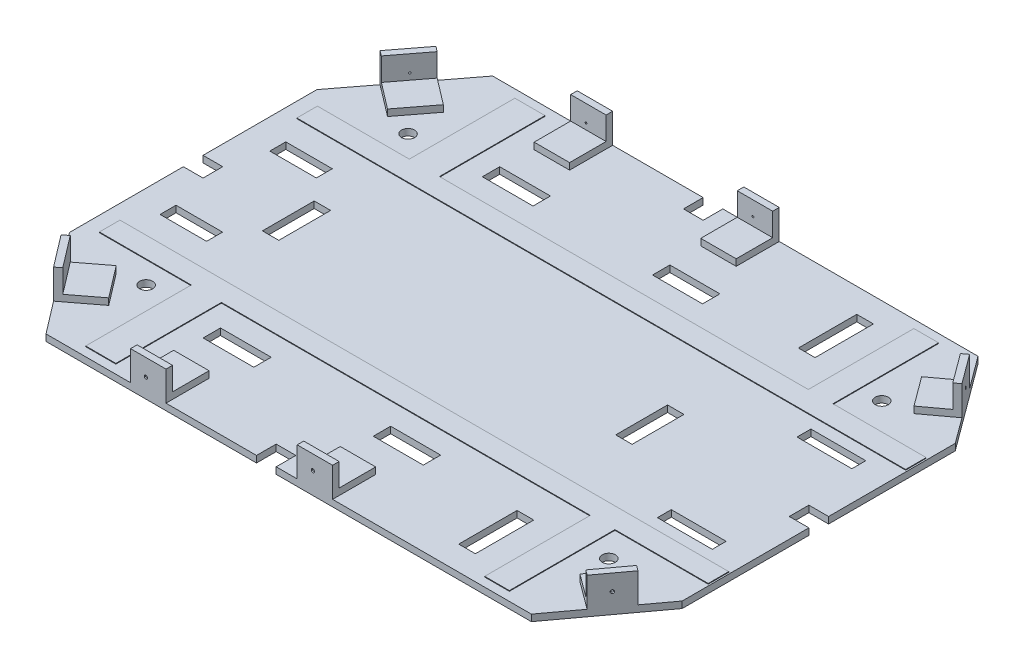
from build123d import *

# Parameters (mm, degrees)
BOSS_EXTRUDE1_DEPTH                               = 10
BOSS_EXTRUDE3_DEPTH                               = 1
SKETCH4_W                                         = 54.012676008
SKETCH4_H                                         = 70.658513541
SKETCH4_W_2                                       = 54
BOSS_EXTRUDE4_DEPTH                               = 10
SKETCH5_W                                         = 54
SKETCH5_H                                         = 56.816879392
SKETCH5_W_2                                       = 54.121672763
BOSS_EXTRUDE6_DEPTH                               = 3
SKETCH6_R                                         = 3
CUT_EXTRUDE1_DEPTH                                = 3
BOSS_EXTRUDE7_DEPTH                               = 3
SKETCH8_R                                         = 3
CUT_EXTRUDE6_DEPTH                                = 10
SKETCH9_W                                         = 60.69706817
SKETCH9_H                                         = 59.255494523
BOSS_EXTRUDE8_DEPTH                               = 3
SKETCH10_R                                        = 3
CUT_EXTRUDE7_DEPTH                                = 10
SKETCH12_R                                        = 10
SKETCH12_W                                        = 77.312261737
SKETCH12_H                                        = 26.476801965
SKETCH12_W_2                                      = 76.253189659
SKETCH12_W_3                                      = 25.417729886
SKETCH12_H_2                                      = 88.962054601
SKETCH12_W_4                                      = 83.666694209
SKETCH12_H_3                                      = 21.181441572
SKETCH12_W_5                                      = 70.957829266
SKETCH12_H_4                                      = 24.358657807
SKETCH12_W_6                                      = 25
SKETCH12_H_5                                      = 75
CUT_EXTRUDE8_DEPTH                                = 10
SKETCH13_W                                        = 30
SKETCH13_H                                        = 20
SKETCH13_W_2                                      = 20
SKETCH13_H_2                                      = 30
CUT_EXTRUDE9_DEPTH                                = 11
CUT_EXTRUDE11_DEPTH                               = 70
CUT_EXTRUDE11_DEPTH_BACK                          = 10
SKETCH16_W                                        = 54.012676008
SKETCH16_H                                        = 45
SKETCH16_W_2                                      = 54
BOSS_EXTRUDE9_DEPTH                               = 10
SKETCH18_W                                        = 60.806808494
SKETCH18_H                                        = 45
BOSS_EXTRUDE10_DEPTH                              = 10
CSK_FOR_3_FLAT_HEAD_MACHINE_SCREW_100_D           = 2.794
CSK_FOR_3_FLAT_HEAD_MACHINE_SCREW_100_DEPTH       = 10
CSK_FOR_3_FLAT_HEAD_MACHINE_SCREW_100_CSINK_D     = 5.0546
CSK_FOR_3_FLAT_HEAD_MACHINE_SCREW_100_CSINK_ANGLE = 100
SKETCH20_W                                        = 55.396415353
SKETCH20_H                                        = 45
BOSS_EXTRUDE11_DEPTH                              = 10
CSK_FOR_3_FLAT_HEAD_MACHINE_SCREW_2_D             = 2.794
CSK_FOR_3_FLAT_HEAD_MACHINE_SCREW_2_DEPTH         = 10
CSK_FOR_3_FLAT_HEAD_MACHINE_SCREW_2_CSINK_D       = 5.0546
CSK_FOR_3_FLAT_HEAD_MACHINE_SCREW_2_CSINK_ANGLE   = 100
CSK_FOR_3_FLAT_HEAD_MACHINE_SCREW_3_D             = 2.794
CSK_FOR_3_FLAT_HEAD_MACHINE_SCREW_3_DEPTH         = 10
CSK_FOR_3_FLAT_HEAD_MACHINE_SCREW_3_CSINK_D       = 5.0546
CSK_FOR_3_FLAT_HEAD_MACHINE_SCREW_3_CSINK_ANGLE   = 100


with BuildPart() as part:
    # Sketch2 → Boss-Extrude1 (new body)
    with BuildSketch(Plane(origin=(0, 0, 0), x_dir=(1, 0, 0), z_dir=(0, 1, 0))):
        Polygon((0, -190.295), (0, 190.295), (118.58, 345.487717935), (863.58, 345.487717935), (963.71, 209.828898833), (963.71, -209.828898833), (863.58, -345.487717935), (118.58, -345.487717935), align=None)
    extrude(amount=BOSS_EXTRUDE1_DEPTH)

    # Sketch3 → Boss-Extrude3 (add)
    with BuildSketch(Plane(origin=(0, 10, 0), x_dir=(1, 0, 0), z_dir=(0, 1, 0))):
        Polygon((28.17698589, 166.19612069), (168.241641063, 166.19612069), (168.241641063, 327.165948276), (214.233020373, 327.165948276), (214.233020373, 166.19612069), (776.582158304, 166.19612069), (776.582158304, 327.165948276), (814.211468649, 327.165948276), (814.211468649, 166.19612069), (956.366641063, 166.19612069), (956.366641063, 134.838362069), (28.17698589, 134.838362069), align=None)
        Polygon((28.17698589, -166.19612069), (28.17698589, -134.838362069), (956.366641063, -134.838362069), (956.366641063, -166.19612069), (814.211468649, -166.19612069), (814.211468649, -327.165948276), (776.582158304, -327.165948276), (776.582158304, -166.19612069), (214.233020373, -166.19612069), (214.233020373, -327.165948276), (168.241641063, -327.165948276), (168.241641063, -166.19612069), align=None)
    extrude(amount=BOSS_EXTRUDE3_DEPTH)

    # Sketch4 → Boss-Extrude4 (add)
    with BuildSketch(Plane(origin=(0, 10, 0), x_dir=(1, 0, 0), z_dir=(0, 1, 0))):
        with Locations((277.006338004, 310.158461165)):
            Rectangle(SKETCH4_W, SKETCH4_H)
        with Locations((531.012676008, 310.158461165)):
            Rectangle(SKETCH4_W_2, SKETCH4_H)
        Polygon((42.789166451, 246.295734017), (94.437964084, 206.831804878), (131.289422503, 255.061506276), (79.640624869, 294.525435415), align=None)
        Polygon((901.195345486, 294.525435415), (855.113704325, 260.512499433), (888.011178195, 215.942116364), (934.092819357, 249.955052346), align=None)
        with Locations((531.012676008, -310.158461165)):
            Rectangle(SKETCH4_W_2, SKETCH4_H)
        Polygon((42.789166451, -246.295734017), (94.437964084, -206.831804878), (131.289422503, -255.061506276), (79.640624869, -294.525435415), align=None)
        Polygon((901.195345486, -294.525435415), (855.113704325, -260.512499433), (888.011178195, -215.942116364), (934.092819357, -249.955052346), align=None)
        with Locations((277.006338004, -310.158461165)):
            Rectangle(SKETCH4_W, SKETCH4_H)
    extrude(amount=BOSS_EXTRUDE4_DEPTH)

    # Sketch5 → Boss-Extrude6 (add)
    with BuildSketch(Plane.XY.offset(345.487717935)):
        with Locations((277, 38.408439696)):
            Rectangle(SKETCH5_W, SKETCH5_H)
        with Locations((531.07351239, 38.408439696)):
            Rectangle(SKETCH5_W_2, SKETCH5_H)
    boss_extrude6 = extrude(amount=-BOSS_EXTRUDE6_DEPTH)

    # Sketch6 → Cut-Extrude1 (cut)
    with BuildSketch(Plane.XY.offset(345.487717935)):
        with Locations((277, 40.573565098)):
            Circle(SKETCH6_R)
        with Locations((531.134348771, 40.573565098)):
            Circle(SKETCH6_R)
    cut_extrude1 = extrude(amount=-CUT_EXTRUDE1_DEPTH, mode=Mode.SUBTRACT)

    # Mirror3: Boss-Extrude6, Cut-Extrude1 across plane
    add(boss_extrude6.mirror(Plane.XY))
    add(cut_extrude1.mirror(Plane.XY), mode=Mode.SUBTRACT)

    # Sketch7 → Boss-Extrude7 (add)
    with BuildSketch(Plane(origin=(724.099790673, 0, 534.459259784), x_dir=(0.593855643, 0, -0.80457161), z_dir=(0.80457161, 0, 0.593855643))):
        Polygon((298.213137891, 10), (298.213137891, 0), (353.439734487, 0), (353.439734487, 10), (353.439734487, 60.62673412), (298.213137891, 60.62673412), align=None)
    boss_extrude7 = extrude(amount=-BOSS_EXTRUDE7_DEPTH)

    # Sketch8 → Cut-Extrude6 (cut)
    with BuildSketch(Plane(origin=(721.686075844, 0, 532.677692854), x_dir=(-0.593855643, 0, 0.80457161), z_dir=(-0.80457161, 0, -0.593855643))):
        with Locations((-325.213137891, 37)):
            Circle(SKETCH8_R)
    cut_extrude6 = extrude(amount=-CUT_EXTRUDE6_DEPTH, mode=Mode.SUBTRACT)

    # Sketch9 → Boss-Extrude8 (add)
    with BuildSketch(Plane(origin=(-91.803915054, 0, 70.14574132), x_dir=(0.607137371, 0, 0.794596887), z_dir=(-0.794596887, 0, 0.607137371))):
        with Locations((252.033259576, 29.627747262)):
            Rectangle(SKETCH9_W, SKETCH9_H)
    boss_extrude8 = extrude(amount=-BOSS_EXTRUDE8_DEPTH)

    # Sketch10 → Cut-Extrude7 (cut)
    with BuildSketch(Plane(origin=(-91.803915054, 0, 70.14574132), x_dir=(0.607137371, 0, 0.794596887), z_dir=(-0.794596887, 0, 0.607137371))):
        with Locations((255.381793661, 38.737565601)):
            Circle(SKETCH10_R)
    cut_extrude7 = extrude(amount=-CUT_EXTRUDE7_DEPTH, mode=Mode.SUBTRACT)

    # Mirror4: Boss-Extrude7, Cut-Extrude6, Boss-Extrude8, Cut-Extrude7 across plane
    add(boss_extrude7.mirror(Plane.XY))
    add(cut_extrude6.mirror(Plane.XY), mode=Mode.SUBTRACT)
    add(boss_extrude8.mirror(Plane.XY))
    add(cut_extrude7.mirror(Plane.XY), mode=Mode.SUBTRACT)

    # Sketch12 → Cut-Extrude8 (cut)
    with BuildSketch(Plane(origin=(0, 10, 0), x_dir=(1, 0, 0), z_dir=(0, 1, 0))):
        with Locations((132.890750104, 199.635086814)):
            Circle(SKETCH12_R)
        with Locations((846.705331075, 208.107663443)):
            Circle(SKETCH12_R)
        with Locations((284.867593382, 212.873487797)):
            Rectangle(SKETCH12_W, SKETCH12_H)
        with Locations((543.810716598, 212.873487797)):
            Rectangle(SKETCH12_W_2, SKETCH12_H)
        with Locations((725.971114115, 258.943123216)):
            Rectangle(SKETCH12_W_3, SKETCH12_H_2)
        with Locations((871.593524922, 106.436743898)):
            Rectangle(SKETCH12_W_4, SKETCH12_H_3)
        with Locations((85.762042607, 83.666694209)):
            Rectangle(SKETCH12_W_5, SKETCH12_H_4)
        with Locations((162.5, -2.012282065)):
            Rectangle(SKETCH12_W_6, SKETCH12_H_5)
        with Locations((701.21, -2.012282065)):
            Rectangle(SKETCH12_W_6, SKETCH12_H_5)
    cut_extrude8 = extrude(amount=-CUT_EXTRUDE8_DEPTH, mode=Mode.SUBTRACT)

    # Mirror5: Cut-Extrude8 across plane
    add(cut_extrude8.mirror(Plane.XY), mode=Mode.SUBTRACT)

    # Sketch13 → Cut-Extrude9 (cut, through all)
    with BuildSketch(Plane(origin=(0, 10, 0), x_dir=(1, 0, 0), z_dir=(0, 1, 0))):
        with Locations((15, 0)):
            Rectangle(SKETCH13_W, SKETCH13_H)
        with Locations((948.71, 0)):
            Rectangle(SKETCH13_W, SKETCH13_H)
        with Locations((457, -330.487717935)):
            Rectangle(SKETCH13_W_2, SKETCH13_H_2)
        with Locations((457, 330.487717935)):
            Rectangle(SKETCH13_W_2, SKETCH13_H_2)
    extrude(amount=-CUT_EXTRUDE9_DEPTH, mode=Mode.SUBTRACT)

    # Sketch15 → Cut-Extrude11 (cut, two sides)
    with BuildSketch(Plane(origin=(0, 10, 0), x_dir=(1, 0, 0), z_dir=(0, 1, 0))) as cut_extrude11_sk:
        Polygon((0, 10), (30, 10), (30, -10), (0, -10), (0, -190.295), (118.58, -345.487717935), (447, -345.487717935), (447, -315.487717935), (467, -315.487717935), (467, -345.487717935), (863.58, -345.487717935), (963.71, -209.828898833), (963.71, -10), (933.71, -10), (933.71, 10), (963.71, 10), (963.71, 209.828898833), (863.58, 345.487717935), (467, 345.487717935), (467, 315.487717935), (447, 315.487717935), (447, 345.487717935), (118.58, 345.487717935), (0, 190.295), align=None)
        Polygon((5, 188.603429665), (5, 15), (35, 15), (35, -15), (5, -15), (5, -188.603429665), (121.052087641, -340.487717935), (442, -340.487717935), (442, -310.487717935), (472, -310.487717935), (472, -340.487717935), (861.056021078, -340.487717935), (958.71, -208.183478834), (958.71, -15), (928.71, -15), (928.71, 15), (958.71, 15), (958.71, 208.183478834), (861.056021078, 340.487717935), (472, 340.487717935), (472, 310.487717935), (442, 310.487717935), (442, 340.487717935), (121.052087641, 340.487717935), align=None, mode=Mode.SUBTRACT)
    extrude(amount=CUT_EXTRUDE11_DEPTH, mode=Mode.SUBTRACT)
    extrude(cut_extrude11_sk.sketch, amount=-CUT_EXTRUDE11_DEPTH_BACK, mode=Mode.SUBTRACT)

    # Sketch16 → Boss-Extrude9 (add)
    with BuildSketch(Plane.XY.offset(340.487717935)):
        with Locations((277.006338004, 32.5)):
            Rectangle(SKETCH16_W, SKETCH16_H)
        with Locations((531.012676008, 32.5)):
            Rectangle(SKETCH16_W_2, SKETCH16_H)
    boss_extrude9 = extrude(amount=-BOSS_EXTRUDE9_DEPTH)

    # Sketch18 → Boss-Extrude10 (add)
    with BuildSketch(Plane(origin=(-87.83093062, 0, 67.110054464), x_dir=(0.607137371, 0, 0.794596887), z_dir=(-0.794596887, 0, 0.607137371))):
        with Locations((251.978389414, 32.5)):
            Rectangle(SKETCH18_W, SKETCH18_H)
    boss_extrude10 = extrude(amount=-BOSS_EXTRUDE10_DEPTH)

    # CSK for _3 Flat Head Machine Screw _100
    with Locations(Plane(origin=(65.518318411, 29.76755003, 267.807362192), x_dir=(-0.607137371, 0, -0.794596887), z_dir=(-0.794596887, 0, 0.607137371))):
        with Locations((0, 0)):
            csk_for_3_flat_head_machine_screw_100 = CounterSinkHole(CSK_FOR_3_FLAT_HEAD_MACHINE_SCREW_100_D / 2, CSK_FOR_3_FLAT_HEAD_MACHINE_SCREW_100_CSINK_D / 2, depth=CSK_FOR_3_FLAT_HEAD_MACHINE_SCREW_100_DEPTH, counter_sink_angle=CSK_FOR_3_FLAT_HEAD_MACHINE_SCREW_100_CSINK_ANGLE)

    # Sketch20 → Boss-Extrude11 (add)
    with BuildSketch(Plane(origin=(720.076932625, 0, 531.489981568), x_dir=(0.593855643, 0, -0.80457161), z_dir=(0.80457161, 0, 0.593855643))):
        with Locations((325.911345568, 32.5)):
            Rectangle(SKETCH20_W, SKETCH20_H)
    boss_extrude11 = extrude(amount=-BOSS_EXTRUDE11_DEPTH)

    # CSK for _3 Flat Head Machine Screw _ 2
    with Locations(Plane(origin=(913.525152228, 30.408146021, 269.401126792), x_dir=(-0.593855643, 0, 0.80457161), z_dir=(0.80457161, 0, 0.593855643))):
        with Locations((0, 0)):
            csk_for_3_flat_head_machine_screw_2 = CounterSinkHole(CSK_FOR_3_FLAT_HEAD_MACHINE_SCREW_2_D / 2, CSK_FOR_3_FLAT_HEAD_MACHINE_SCREW_2_CSINK_D / 2, depth=CSK_FOR_3_FLAT_HEAD_MACHINE_SCREW_2_DEPTH, counter_sink_angle=CSK_FOR_3_FLAT_HEAD_MACHINE_SCREW_2_CSINK_ANGLE)

    # CSK for _3 Flat Head Machine Screw _ 3
    with Locations(Plane(origin=(273.418809653, 29.044000032, 340.487717935), x_dir=(1, 0, 0), z_dir=(0, 0, 1))):
        with Locations((0, 0), (254.594481949, 3.767959272)):
            csk_for_3_flat_head_machine_screw_3 = CounterSinkHole(CSK_FOR_3_FLAT_HEAD_MACHINE_SCREW_3_D / 2, CSK_FOR_3_FLAT_HEAD_MACHINE_SCREW_3_CSINK_D / 2, depth=CSK_FOR_3_FLAT_HEAD_MACHINE_SCREW_3_DEPTH, counter_sink_angle=CSK_FOR_3_FLAT_HEAD_MACHINE_SCREW_3_CSINK_ANGLE)

    # Mirror7: Boss-Extrude9, Boss-Extrude10, CSK for _3 Flat Head Machine Screw _100, Boss-Extrude11, CSK for _3 Flat Head Machine Screw _ 2, CSK for _3 Flat Head Machine Screw _ 3 across plane
    add(boss_extrude9.mirror(Plane.XY))
    add(boss_extrude10.mirror(Plane.XY))
    add(csk_for_3_flat_head_machine_screw_100.mirror(Plane.XY), mode=Mode.SUBTRACT)
    add(boss_extrude11.mirror(Plane.XY))
    add(csk_for_3_flat_head_machine_screw_2.mirror(Plane.XY), mode=Mode.SUBTRACT)
    add(csk_for_3_flat_head_machine_screw_3.mirror(Plane.XY), mode=Mode.SUBTRACT)


solid = part.part
